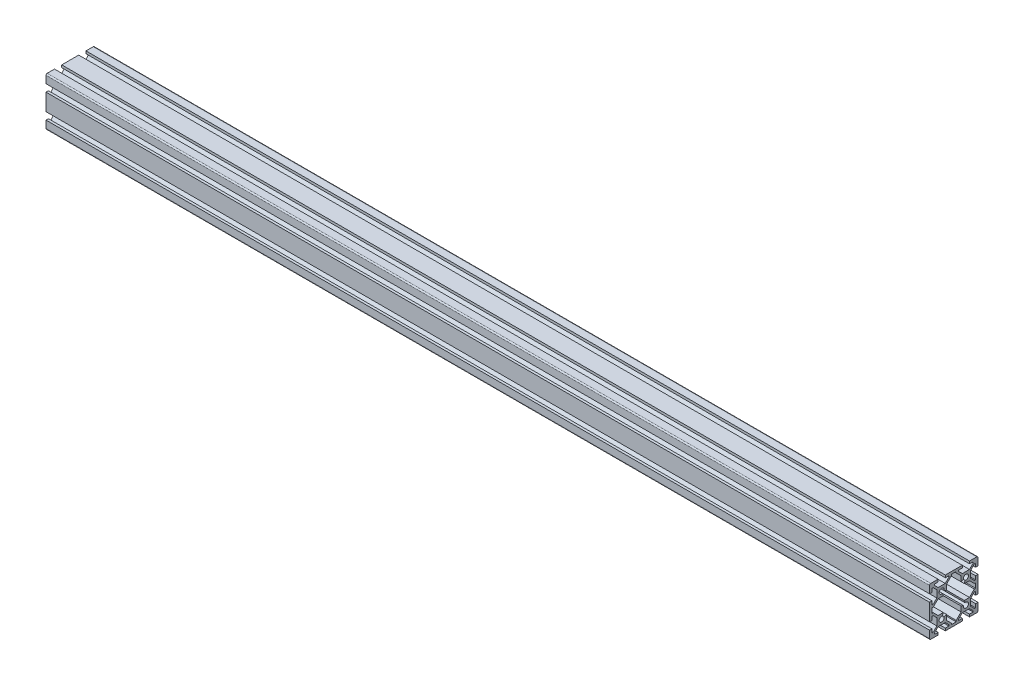
from build123d import *

# Parameters (mm, degrees)
BOSS_EXTRUDE1_DEPTH = 730


with BuildPart() as part:
    # Sketch1 → Boss-Extrude1 (new body)
    with BuildSketch(Plane(origin=(0, 0, 0), x_dir=(0, 0, -1), z_dir=(1, 0, 0))):
        with BuildLine():
            Line((-20, 19), (-20, 13))
            Line((-20, 13), (-18, 13))
            Line((-18, 13), (-18, 16))
            Line((-18, 16), (-17.060660172, 16))
            Line((-17.060660172, 16), (-14, 12.939339828))
            Line((-14, 12.939339828), (-14, 7.060660172))
            Line((-14, 7.060660172), (-17.060660172, 4))
            Line((-17.060660172, 4), (-18, 4))
            Line((-18, 4), (-18, 7))
            Line((-18, 7), (-20, 7))
            Line((-20, 7), (-20, -7))
            Line((-20, -7), (-18, -7))
            Line((-18, -7), (-18, -4))
            Line((-18, -4), (-17.060660172, -4))
            Line((-17.060660172, -4), (-14, -7.060660172))
            Line((-14, -7.060660172), (-14, -12.939339828))
            Line((-14, -12.939339828), (-17.060660172, -16))
            Line((-17.060660172, -16), (-18, -16))
            Line((-18, -16), (-18, -13))
            Line((-18, -13), (-20, -13))
            Line((-20, -13), (-20, -19))
            ThreePointArc((-20, -19), (-19.707106781, -19.707106781), (-19, -20))
            Line((-19, -20), (-13, -20))
            Line((-13, -20), (-13, -18))
            Line((-13, -18), (-16, -18))
            Line((-16, -18), (-16, -17.060660172))
            Line((-16, -17.060660172), (-12.939339828, -14))
            Line((-12.939339828, -14), (-7.060660172, -14))
            Line((-7.060660172, -14), (-4, -17.060660172))
            Line((-4, -17.060660172), (-4, -18))
            Line((-4, -18), (-7, -18))
            Line((-7, -18), (-7, -20))
            Line((-7, -20), (7, -20))
            Line((7, -20), (7, -18))
            Line((7, -18), (4, -18))
            Line((4, -18), (4, -17.060660172))
            Line((4, -17.060660172), (7.060660172, -14))
            Line((7.060660172, -14), (12.939339828, -14))
            Line((12.939339828, -14), (16, -17.060660172))
            Line((16, -17.060660172), (16, -18))
            Line((16, -18), (13, -18))
            Line((13, -18), (13, -20))
            Line((13, -20), (19, -20))
            ThreePointArc((19, -20), (19.707106781, -19.707106781), (20, -19))
            Line((20, -19), (20, -13))
            Line((20, -13), (18, -13))
            Line((18, -13), (18, -16))
            Line((18, -16), (17.060660172, -16))
            Line((17.060660172, -16), (14, -12.939339828))
            Line((14, -12.939339828), (14, -7.060660172))
            Line((14, -7.060660172), (17.060660172, -4))
            Line((17.060660172, -4), (18, -4))
            Line((18, -4), (18, -7))
            Line((18, -7), (20, -7))
            Line((20, -7), (20, 7))
            Line((20, 7), (18, 7))
            Line((18, 7), (18, 4))
            Line((18, 4), (17.060660172, 4))
            Line((17.060660172, 4), (14, 7.060660172))
            Line((14, 7.060660172), (14, 12.939339828))
            Line((14, 12.939339828), (17.060660172, 16))
            Line((17.060660172, 16), (18, 16))
            Line((18, 16), (18, 13))
            Line((18, 13), (20, 13))
            Line((20, 13), (20, 19))
            ThreePointArc((20, 19), (19.707106781, 19.707106781), (19, 20))
            Line((19, 20), (13, 20))
            Line((13, 20), (13, 18))
            Line((13, 18), (16, 18))
            Line((16, 18), (16, 17.060660172))
            Line((16, 17.060660172), (12.939339828, 14))
            Line((12.939339828, 14), (7.060660172, 14))
            Line((7.060660172, 14), (4, 17.060660172))
            Line((4, 17.060660172), (4, 18))
            Line((4, 18), (7, 18))
            Line((7, 18), (7, 20))
            Line((7, 20), (-7, 20))
            Line((-7, 20), (-7, 18))
            Line((-7, 18), (-4, 18))
            Line((-4, 18), (-4, 17.060660172))
            Line((-4, 17.060660172), (-7.060660172, 14))
            Line((-7.060660172, 14), (-12.939339828, 14))
            Line((-12.939339828, 14), (-16, 17.060660172))
            Line((-16, 17.060660172), (-16, 18))
            Line((-16, 18), (-13, 18))
            Line((-13, 18), (-13, 20))
            Line((-13, 20), (-19, 20))
            ThreePointArc((-19, 20), (-19.707106781, 19.707106781), (-20, 19))
        make_face()
        with BuildLine():
            Line((-16.939339828, 2), (-18, 2))
            Line((-18, 2), (-18, -2))
            Line((-18, -2), (-16.939339828, -2))
            Line((-16.939339828, -2), (-12.939339828, -6))
            Line((-12.939339828, -6), (-8.666662697, -6))
            Line((-8.666662697, -6), (-9.335919912, -8.007765667))
            ThreePointArc((-9.335919912, -8.007765667), (-11.48492424, -11.48492424), (-8.007765667, -9.335919912))
            Line((-8.007765667, -9.335919912), (-6, -8.666662697))
            Line((-6, -8.666662697), (-6, -12.939339828))
            Line((-6, -12.939339828), (-2, -16.939339828))
            Line((-2, -16.939339828), (-2, -18))
            Line((-2, -18), (2, -18))
            Line((2, -18), (2, -16.939339828))
            Line((2, -16.939339828), (6, -12.939339828))
            Line((6, -12.939339828), (6, -8.666662697))
            Line((6, -8.666662697), (8.007765667, -9.335919912))
            ThreePointArc((8.007765667, -9.335919912), (11.48492424, -11.48492424), (9.335919912, -8.007765667))
            Line((9.335919912, -8.007765667), (8.666662697, -6))
            Line((8.666662697, -6), (12.939339828, -6))
            Line((12.939339828, -6), (16.939339828, -2))
            Line((16.939339828, -2), (18, -2))
            Line((18, -2), (18, 2))
            Line((18, 2), (16.939339828, 2))
            Line((16.939339828, 2), (12.939339828, 6))
            Line((12.939339828, 6), (8.666662697, 6))
            Line((8.666662697, 6), (9.335919912, 8.007765667))
            ThreePointArc((9.335919912, 8.007765667), (11.48492424, 11.48492424), (8.007765667, 9.335919912))
            Line((8.007765667, 9.335919912), (6, 8.666662697))
            Line((6, 8.666662697), (6, 12.939339828))
            Line((6, 12.939339828), (2, 16.939339828))
            Line((2, 16.939339828), (2, 18))
            Line((2, 18), (-2, 18))
            Line((-2, 18), (-2, 16.939339828))
            Line((-2, 16.939339828), (-6, 12.939339828))
            Line((-6, 12.939339828), (-6, 8.666662697))
            Line((-6, 8.666662697), (-8.007765667, 9.335919912))
            ThreePointArc((-8.007765667, 9.335919912), (-11.48492424, 11.48492424), (-9.335919912, 8.007765667))
            Line((-9.335919912, 8.007765667), (-8.666662697, 6))
            Line((-8.666662697, 6), (-12.939339828, 6))
            Line((-12.939339828, 6), (-16.939339828, 2))
        make_face(mode=Mode.SUBTRACT)
    extrude(amount=BOSS_EXTRUDE1_DEPTH)


solid = part.part
